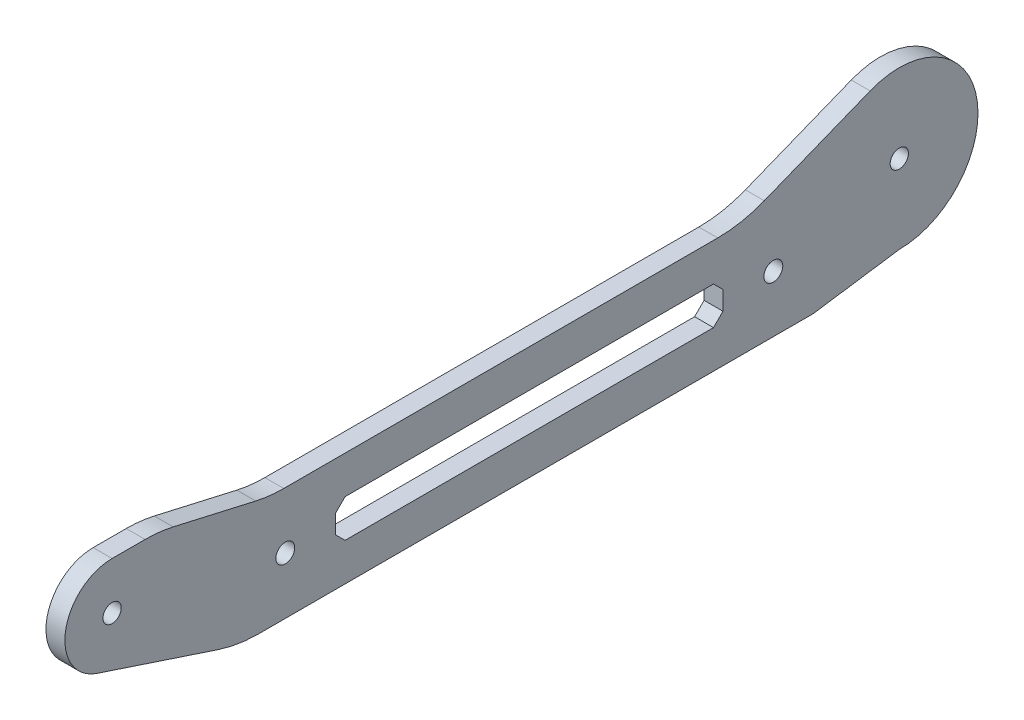
from build123d import *

# Parameters (mm, degrees)
SKETCH1_R           = 1.5
SKETCH1_R_2         = 1.45
BOSS_EXTRUDE1_DEPTH = 1.5
FILLET1_R           = 20


with BuildPart() as part:
    # Sketch1 → Boss-Extrude1 (new body, symmetric)
    with BuildSketch(Plane(origin=(0, 0, 0), x_dir=(0, 0, -1), z_dir=(1, 0, 0))):
        with BuildLine():
            Line((-127.350956164, -7.122008503), (-105, -14.5))
            Line((-105, -14.5), (-13.675, -14.5))
            Line((-13.675, -14.5), (0, -12.5))
            ThreePointArc((0, -12.5), (12.276307634, 2.354202809), (-4.624146867, 11.613236661))
            Line((-4.624146867, 11.613236661), (-25, 3.5))
            Line((-25, 3.5), (-100, 3.5))
            Line((-100, 3.5), (-117.5, 7.5))
            Line((-117.5, 7.5), (-125, 7.5))
            ThreePointArc((-125, 7.5), (-132.404899181, 1.190574699), (-127.350956164, -7.122008503))
        make_face()
        with Locations((-97.5, -5.5)):
            Circle(SKETCH1_R, mode=Mode.SUBTRACT)
        Polygon((-89.5, -7), (-89.5, -4), (-88, -2.5), (-29.5, -2.5), (-28, -4), (-28, -7), (-29.5, -8.5), (-88, -8.5), align=None, mode=Mode.SUBTRACT)
        with Locations((-20, -5.5)):
            Circle(SKETCH1_R, mode=Mode.SUBTRACT)
        with Locations((-125, 0)):
            Circle(SKETCH1_R_2, mode=Mode.SUBTRACT)
        Circle(SKETCH1_R_2, mode=Mode.SUBTRACT)
    extrude(amount=BOSS_EXTRUDE1_DEPTH, both=True)

    # Fillet1
    fillet1_edges = [part.edges().sort_by_distance(p)[0] for p in [
        (0, -14.5, 105),
        (0, 7.5, 117.5),
        (0, 3.5, 100),
        (0, 3.5, 25),
    ]]
    fillet(fillet1_edges, radius=FILLET1_R)


solid = part.part
